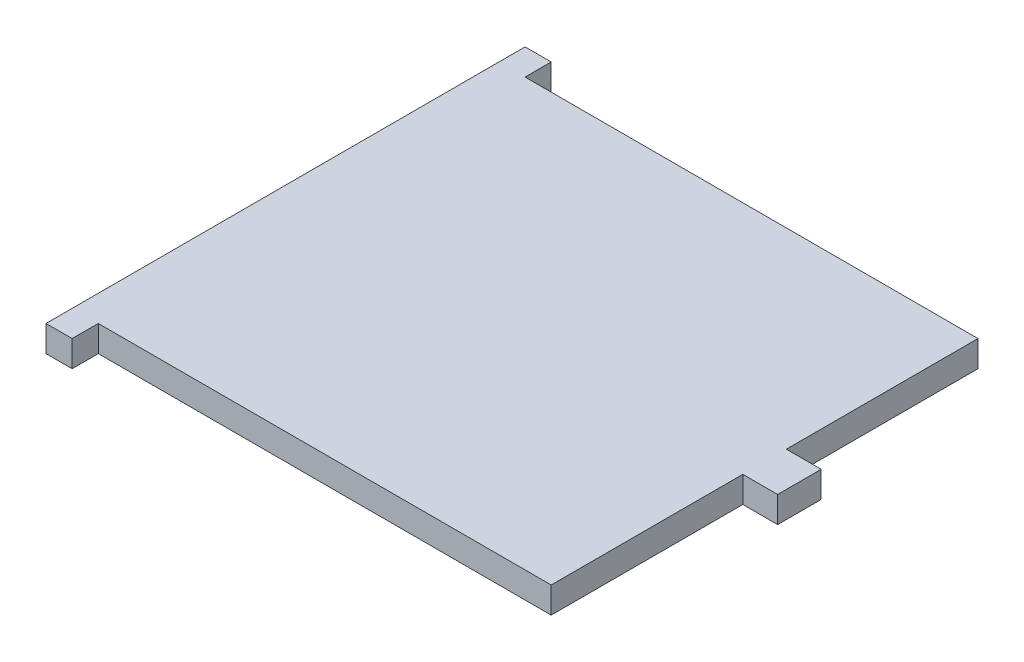
from build123d import *

# Parameters (mm, degrees)
SKETCH1_W           = 49
SKETCH1_H           = 49
SKETCH1_W_2         = 4
SKETCH1_H_2         = 5
SKETCH1_W_3         = 3
BOSS_EXTRUDE1_DEPTH = 3


with BuildPart() as part:
    # Sketch1 → Boss-Extrude1 (new body)
    with BuildSketch(Plane(origin=(0, 0, 0), x_dir=(1, 0, 0), z_dir=(0, 1, 0))):
        Rectangle(SKETCH1_W, SKETCH1_H)
        with Locations((26.5, 0)):
            Rectangle(SKETCH1_W_2, SKETCH1_H_2)
        Polygon((-27.5, 27.5), (-27.5, 24.5), (-27.5, -24.5), (-27.5, -27.5), (-30.5, -27.5), (-30.5, 27.5), align=None)
        with Locations((-26, 0)):
            Rectangle(SKETCH1_W_3, SKETCH1_H)
    extrude(amount=BOSS_EXTRUDE1_DEPTH)


solid = part.part
